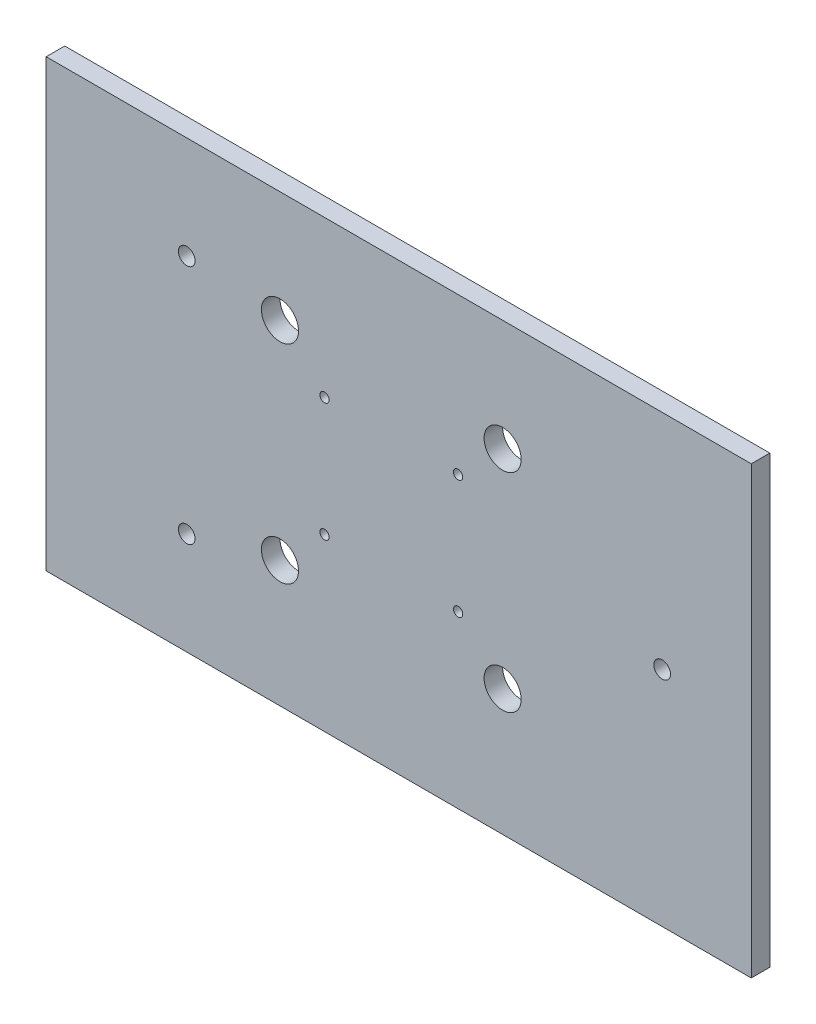
from build123d import *

# Parameters (mm, degrees)
CROQUIS1_W              = 190
CROQUIS1_H              = 120
CROQUIS1_R              = 2.25
CROQUIS1_R_2            = 5
CROQUIS1_R_3            = 1.25
SALIENTE_EXTRUIR1_DEPTH = 5


with BuildPart() as part:
    # Croquis1 → Saliente-Extruir1 (new body)
    with BuildSketch(Plane.XY):
        with Locations((-34.5, 32.5)):
            Rectangle(CROQUIS1_W, CROQUIS1_H)
        with Locations((36.5, 32.5)):
            Circle(CROQUIS1_R, mode=Mode.SUBTRACT)
        with Locations((-91.623199077, 0.069259856)):
            Circle(CROQUIS1_R, mode=Mode.SUBTRACT)
        with Locations((-91.623199077, 64.930740144)):
            Circle(CROQUIS1_R, mode=Mode.SUBTRACT)
        with Locations((-66.5, 62.5)):
            Circle(CROQUIS1_R_2, mode=Mode.SUBTRACT)
        with Locations((-6.5, 62.5)):
            Circle(CROQUIS1_R_2, mode=Mode.SUBTRACT)
        with Locations((-6.5, 6.5)):
            Circle(CROQUIS1_R_2, mode=Mode.SUBTRACT)
        with Locations((-66.5, 6.5)):
            Circle(CROQUIS1_R_2, mode=Mode.SUBTRACT)
        with Locations((-54.5, 50.5)):
            Circle(CROQUIS1_R_3, mode=Mode.SUBTRACT)
        with Locations((-18.5, 50.5)):
            Circle(CROQUIS1_R_3, mode=Mode.SUBTRACT)
        with Locations((-18.5, 18.5)):
            Circle(CROQUIS1_R_3, mode=Mode.SUBTRACT)
        with Locations((-54.5, 18.5)):
            Circle(CROQUIS1_R_3, mode=Mode.SUBTRACT)
    extrude(amount=SALIENTE_EXTRUIR1_DEPTH)


solid = part.part
